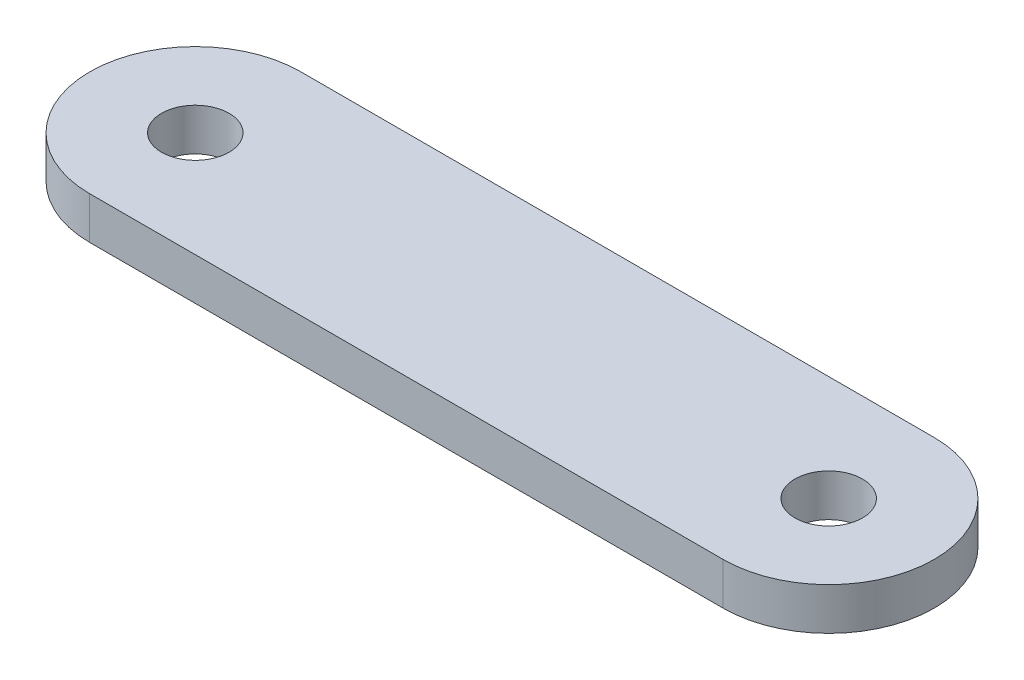
from build123d import *

# Parameters (mm, degrees)
SKETCH_1_R      = 1.6
EXTRUDE_1_DEPTH = 2


with BuildPart() as part:
    # 草图1 → 凸台-拉伸1 (new body)
    with BuildSketch(Plane(origin=(0, 0, 0), x_dir=(1, 0, 0), z_dir=(0, 1, 0))):
        with BuildLine():
            Line((-30, 5), (0, 5))
            ThreePointArc((0, 5), (5, 0), (0, -5))
            Line((0, -5), (-30, -5))
            ThreePointArc((-30, -5), (-35, 0), (-30, 5))
        make_face()
        with Locations((-30, 0)):
            Circle(SKETCH_1_R, mode=Mode.SUBTRACT)
        Circle(SKETCH_1_R, mode=Mode.SUBTRACT)
    extrude(amount=EXTRUDE_1_DEPTH)


solid = part.part
